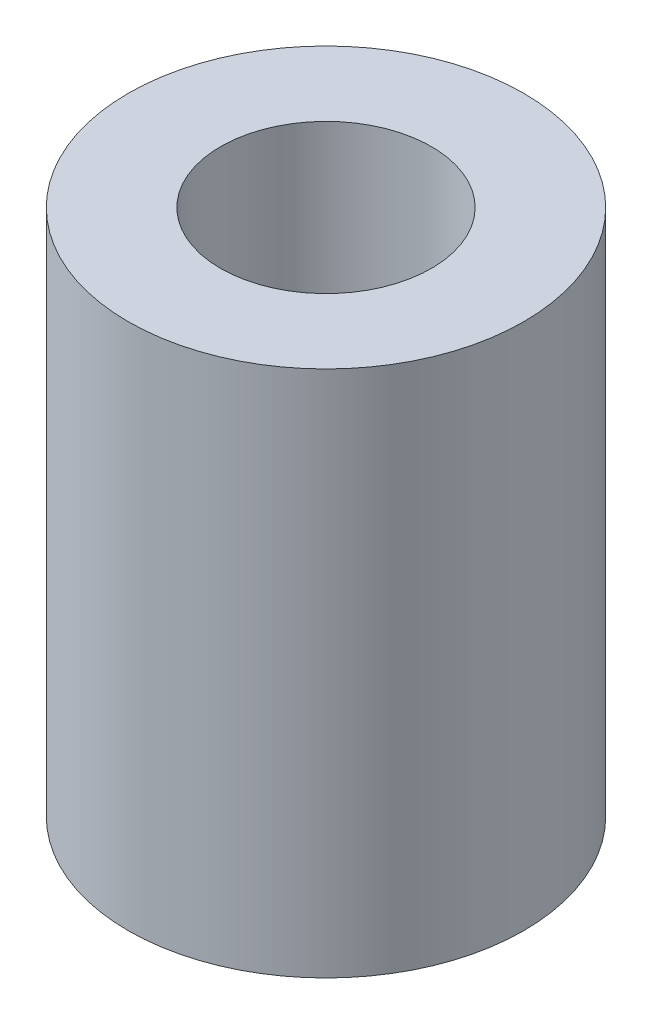
from build123d import *

# Parameters (mm, degrees)
SKETCH1_R           = 3
SKETCH1_R_2         = 1.6
BOSS_EXTRUDE1_DEPTH = 8


with BuildPart() as part:
    # Sketch1 → Boss-Extrude1 (new body)
    with BuildSketch(Plane(origin=(0, 0, 0), x_dir=(1, 0, 0), z_dir=(0, 1, 0))):
        Circle(SKETCH1_R)
        Circle(SKETCH1_R_2, mode=Mode.SUBTRACT)
    extrude(amount=BOSS_EXTRUDE1_DEPTH)


solid = part.part
